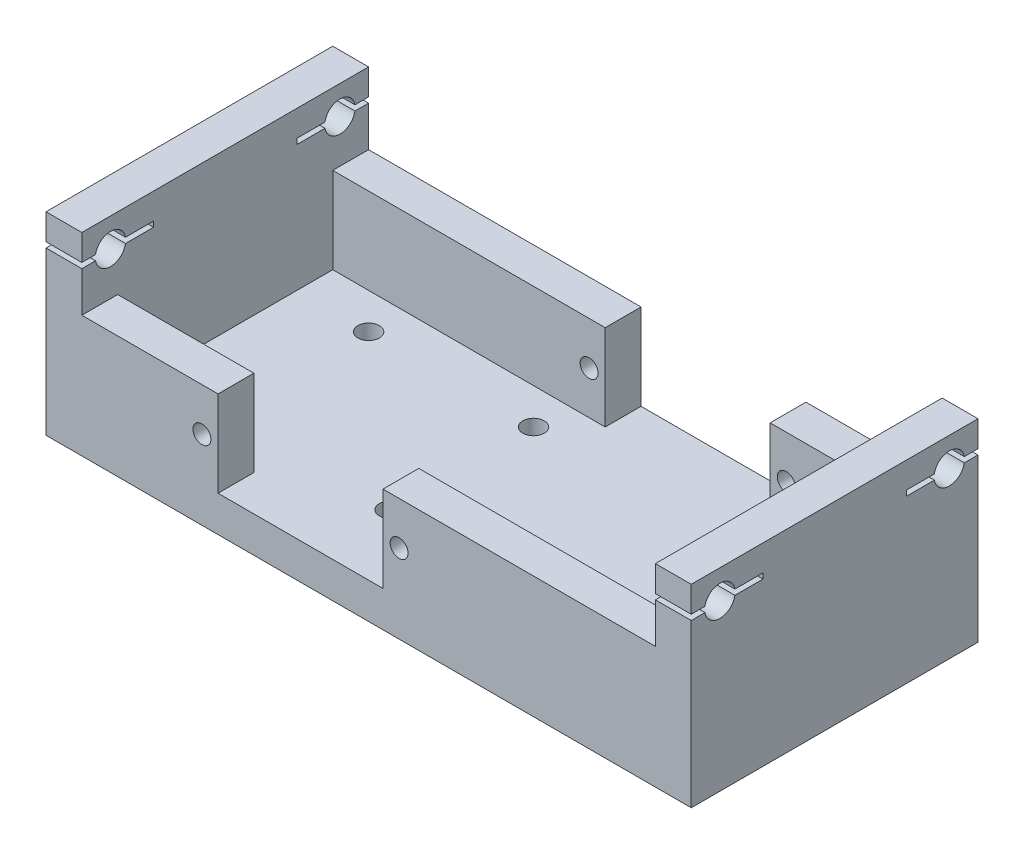
from build123d import *

# Parameters (mm, degrees)
SKETCH1_W           = 90
SKETCH1_H           = 40
BOSS_EXTRUDE1_DEPTH = 5
BOSS_EXTRUDE2_DEPTH = 12
SKETCH3_W           = 5
SKETCH3_H           = 40
BOSS_EXTRUDE3_DEPTH = 10
SKETCH5_R           = 2.125
CUT_EXTRUDE1_DEPTH  = 91
SKETCH7_R           = 1.25
CUT_EXTRUDE3_DEPTH  = 35
SKETCH8_W           = 10
SKETCH8_H           = 0.75
CUT_EXTRUDE4_DEPTH  = 91
SKETCH12_R          = 1.5
CUT_EXTRUDE6_DEPTH  = 28
SKETCH13_R          = 1.25
CUT_EXTRUDE7_DEPTH  = 5


with BuildPart() as part:
    # Sketch1 → Boss-Extrude1 (new body)
    with BuildSketch(Plane(origin=(0, 0, 0), x_dir=(1, 0, 0), z_dir=(0, 1, 0))):
        Rectangle(SKETCH1_W, SKETCH1_H)
    extrude(amount=BOSS_EXTRUDE1_DEPTH)

    # Sketch2 → Boss-Extrude2 (add)
    with BuildSketch(Plane(origin=(0, 5, 0), x_dir=(1, 0, 0), z_dir=(0, 1, 0))):
        Polygon((-21, -20), (-21, -15), (-40, -15), (-40, 15), (-2, 15), (-2, 20), (-45, 20), (-45, -20), align=None)
        Polygon((2, -15), (40, -15), (40, 15), (21, 15), (21, 20), (45, 20), (45, -20), (2, -20), align=None)
    extrude(amount=BOSS_EXTRUDE2_DEPTH)

    # Sketch3 → Boss-Extrude3 (add)
    with BuildSketch(Plane(origin=(0, 17, 0), x_dir=(1, 0, 0), z_dir=(0, 1, 0))):
        with Locations((42.5, 0)):
            Rectangle(SKETCH3_W, SKETCH3_H)
        with Locations((-42.5, 0)):
            Rectangle(SKETCH3_W, SKETCH3_H)
    extrude(amount=BOSS_EXTRUDE3_DEPTH)

    # Sketch5 → Cut-Extrude1 (cut, through all)
    with BuildSketch(Plane.ZY.offset(45)):
        with Locations((16, 23)):
            Circle(SKETCH5_R)
        with Locations((-16, 23)):
            Circle(SKETCH5_R)
    extrude(amount=-CUT_EXTRUDE1_DEPTH, mode=Mode.SUBTRACT)

    # Sketch7 → Cut-Extrude3 (cut)
    with BuildSketch(Plane(origin=(0, 0, 15), x_dir=(-1, 0, 0), z_dir=(0, 0, -1))):
        with Locations((-23.25, 11)):
            Circle(SKETCH7_R)
        with Locations((4.25, 11)):
            Circle(SKETCH7_R)
    extrude(amount=CUT_EXTRUDE3_DEPTH, mode=Mode.SUBTRACT)

    # Sketch8 → Cut-Extrude4 (cut, through all)
    with BuildSketch(Plane.ZY.offset(45)):
        with Locations((15, 23)):
            Rectangle(SKETCH8_W, SKETCH8_H)
        with Locations((-15, 23)):
            Rectangle(SKETCH8_W, SKETCH8_H)
    extrude(amount=-CUT_EXTRUDE4_DEPTH, mode=Mode.SUBTRACT)

    # Sketch12 → Cut-Extrude6 (cut, through all)
    with BuildSketch(Plane.XZ):
        with Locations((-30, 10)):
            Circle(SKETCH12_R)
        with Locations((-30, -10)):
            Circle(SKETCH12_R)
        with Locations((-7, 10)):
            Circle(SKETCH12_R)
        with Locations((-7, -10)):
            Circle(SKETCH12_R)
    extrude(amount=-CUT_EXTRUDE6_DEPTH, mode=Mode.SUBTRACT)

    # Sketch13 → Cut-Extrude7 (cut)
    with BuildSketch(Plane.XY.offset(20)):
        with Locations((-23.25, 11)):
            Circle(SKETCH13_R)
        with Locations((4.25, 11)):
            Circle(SKETCH13_R)
    extrude(amount=-CUT_EXTRUDE7_DEPTH, mode=Mode.SUBTRACT)


solid = part.part
